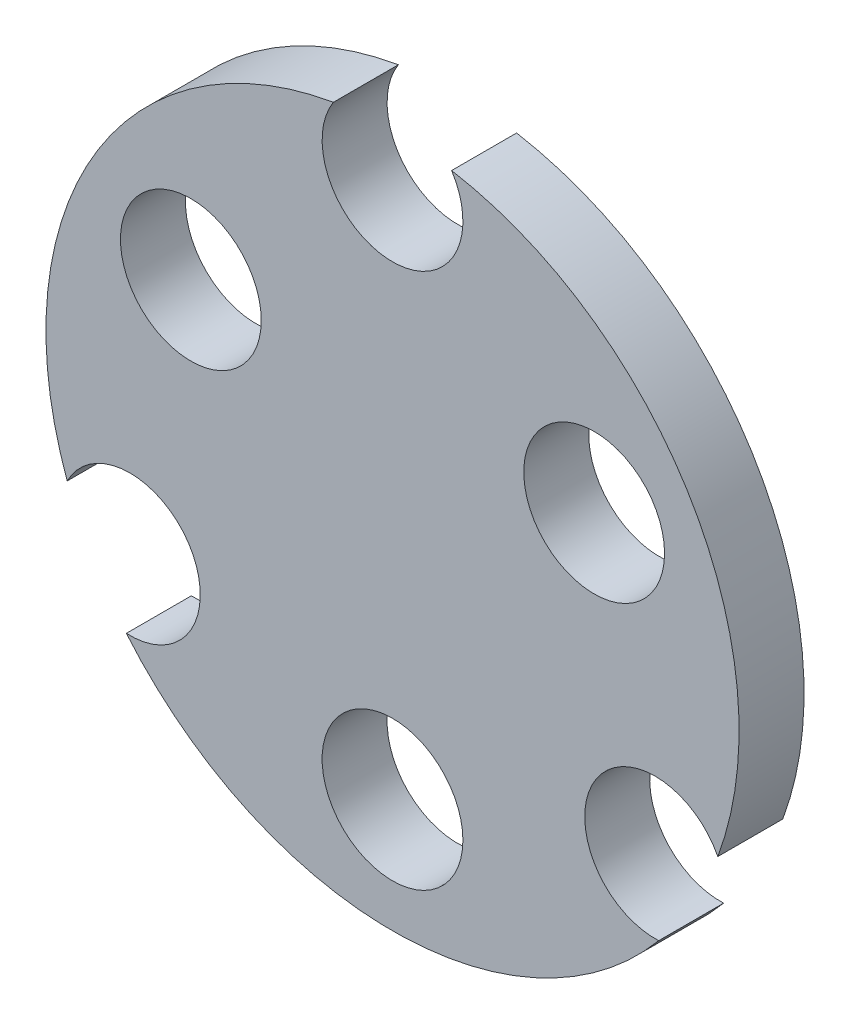
from build123d import *

# Parameters (mm, degrees)
BOSS_EXTRU_2_DEPTH      = 3
ESQUISSE2_R             = 3.25
ENL_V_MAT_EXTRU_1_DEPTH = 10


with BuildPart() as part:
    # Esquisse1 → Boss.-Extru.2 (new body)
    with BuildSketch(Plane.XY):
        with BuildLine():
            ThreePointArc((-12.288149304, -10.247018429), (0.000780623, -15.999999981), (12.289149128, -10.245819328))
            ThreePointArc((12.289149128, -10.245819328), (9.309773091, -5.375), (15.017714385, -5.519805672))
            ThreePointArc((15.017714385, -5.519805672), (13.856406461, 8), (2.728565257, 15.765625))
            ThreePointArc((2.728565257, 15.765625), (0, 10.75), (-2.728565257, 15.765625))
            ThreePointArc((-2.728565257, 15.765625), (-13.856384318, 8.000038352), (-15.01774494, -5.519722539))
            ThreePointArc((-15.01774494, -5.519722539), (-9.310492225, -5.375986513), (-12.288149304, -10.247018429))
        make_face()
    extrude(amount=BOSS_EXTRU_2_DEPTH)

    # Esquisse2 → Enlèv. mat.-Extru.1 (cut)
    with BuildSketch(Plane.XY.offset(3)):
        with Locations((-9.309773091, 5.375)):
            Circle(ESQUISSE2_R)
        with Locations((9.309773091, 5.375)):
            Circle(ESQUISSE2_R)
        with Locations((0, -10.75)):
            Circle(ESQUISSE2_R)
    extrude(amount=-ENL_V_MAT_EXTRU_1_DEPTH, mode=Mode.SUBTRACT)


solid = part.part
